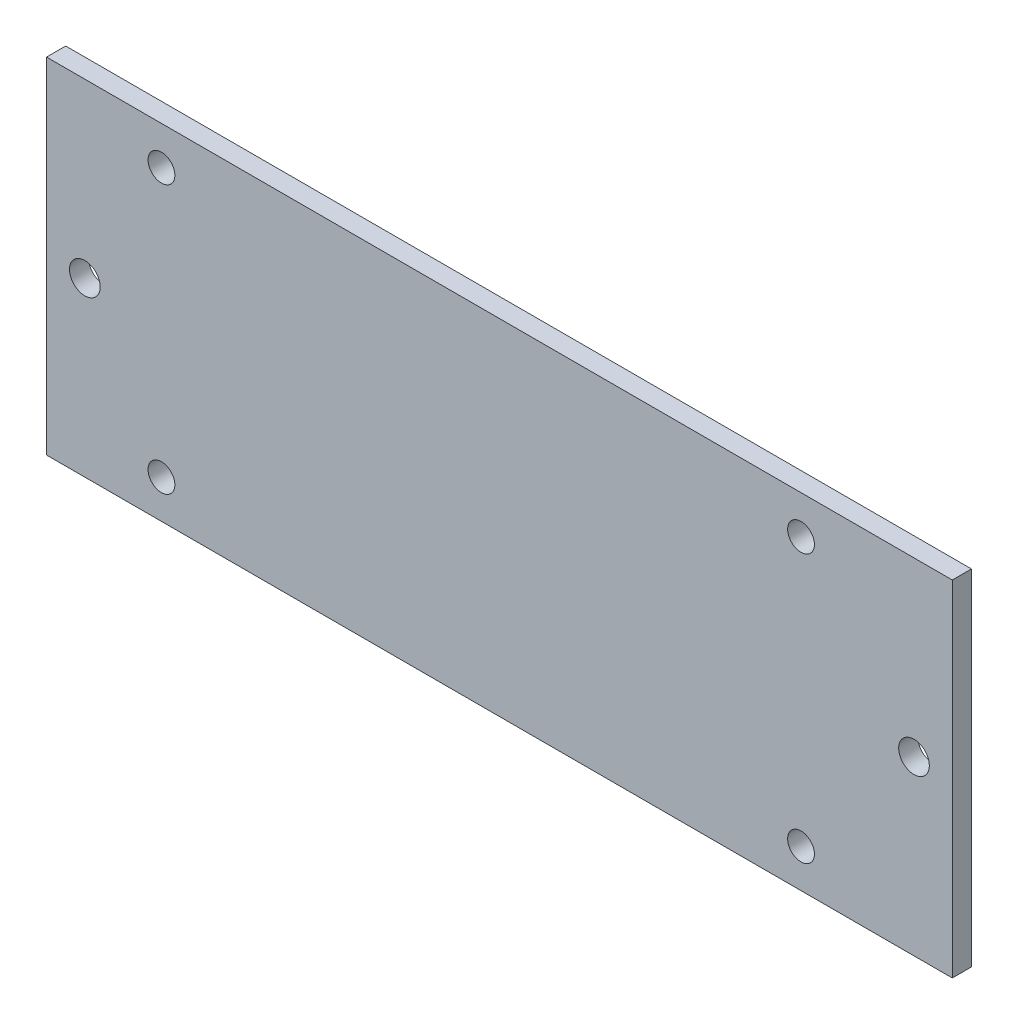
from build123d import *

# Parameters (mm, degrees)
SKETCH1_W           = 60.071
SKETCH1_H           = 22.86
BOSS_EXTRUDE1_DEPTH = 1.27
SKETCH2_R           = 0.889
SKETCH2_R_2         = 1.016
CUT_EXTRUDE1_DEPTH  = 2.54


with BuildPart() as part:
    # Sketch1 → Boss-Extrude1 (new body)
    with BuildSketch(Plane.XY):
        with Locations((-14.931360465, 7.520319767)):
            Rectangle(SKETCH1_W, SKETCH1_H)
    extrude(amount=BOSS_EXTRUDE1_DEPTH)

    # Sketch2 → Cut-Extrude1 (cut)
    with BuildSketch(Plane.XY.offset(1.27)):
        with Locations((-37.346860465, 16.410319767)):
            Circle(SKETCH2_R)
        with Locations((5.071139535, 16.410319767)):
            Circle(SKETCH2_R)
        with Locations((-37.346860465, -1.369680233)):
            Circle(SKETCH2_R)
        with Locations((5.071139535, -1.369680233)):
            Circle(SKETCH2_R)
        with Locations((-42.426860465, 7.520319767)):
            Circle(SKETCH2_R_2)
        with Locations((12.564139535, 7.520319767)):
            Circle(SKETCH2_R_2)
    extrude(amount=-CUT_EXTRUDE1_DEPTH, mode=Mode.SUBTRACT)


solid = part.part
